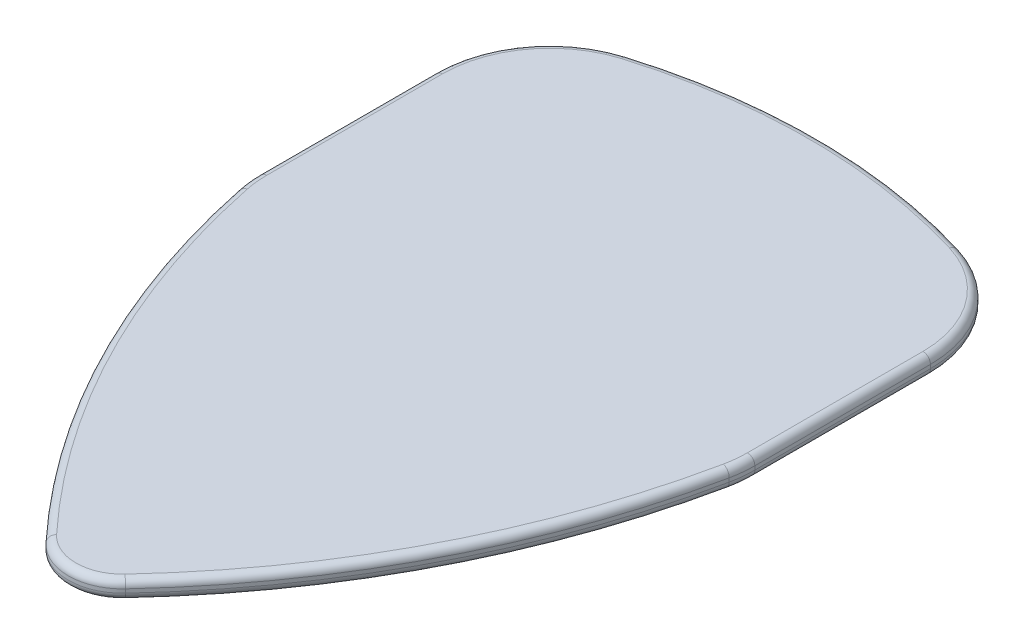
from build123d import *

# Parameters (mm, degrees)
BOSS_EXTRUDE1_DEPTH = 1
BOSS_EXTRUDE2_DEPTH = 1
FILLET1_R           = 0.4


with BuildPart() as part:
    # Sketch1 → Boss-Extrude1 (new body)
    with BuildSketch(Plane(origin=(0, 0, 0), x_dir=(1, 0, 0), z_dir=(0, 1, 0))):
        with BuildLine():
            ThreePointArc((-8.877423872, 29.304875795), (0, 30.62), (8.877423872, 29.304875795))
            ThreePointArc((8.877423872, 29.304875795), (12.375173273, 26.566048159), (13.11, 22.184786084))
            ThreePointArc((13.11, 22.184786084), (9.076207285, 10.799312083), (2.121856975, 0.92320386))
            ThreePointArc((2.121856975, 0.92320386), (0, 0), (-2.121856975, 0.92320386))
            ThreePointArc((-2.121856975, 0.92320386), (-9.076207285, 10.799312083), (-13.11, 22.184786084))
            ThreePointArc((-13.11, 22.184786084), (-12.375173273, 26.566048159), (-8.877423872, 29.304875795))
        make_face()
    extrude(amount=BOSS_EXTRUDE1_DEPTH)

    # Sketch2 → Boss-Extrude2 (add)
    with BuildSketch(Plane(origin=(0, 0, 0), x_dir=(1, 0, 0), z_dir=(0, 1, 0))):
        with BuildLine():
            Line((-13.23730034, 32.808587834), (-13.23730034, 23.428587834))
            Line((-13.23730034, 23.428587834), (13.23730034, 23.428587834))
            Line((13.23730034, 23.428587834), (13.23730034, 32.808587834))
            ThreePointArc((13.23730034, 32.808587834), (12.02830219, 36.467114963), (8.877423872, 38.684875795))
            ThreePointArc((8.877423872, 38.684875795), (0, 40), (-8.877423872, 38.684875795))
            ThreePointArc((-8.877423872, 38.684875795), (-12.02830219, 36.467114963), (-13.23730034, 32.808587834))
        make_face()
    extrude(amount=BOSS_EXTRUDE2_DEPTH)

    # Fillet1
    fillet1_edges = [part.edges().sort_by_distance(p)[0] for p in [
        (0, 1, 0),
        (9.076207285, 1, -10.799312083),
        (-13.205392346, 0, -22.803438218),
        (-13.205392346, 1, -22.803438218),
        (13.205392346, 1, -22.803438218),
        (-12.02830219, 0, -36.467114963),
        (-13.23730034, 0, -28.118587834),
        (13.23730034, 1, -28.118587834),
        (12.02830219, 0, -36.467114963),
        (0, 1, -40),
        (12.02830219, 1, -36.467114963),
        (-12.02830219, 1, -36.467114963),
        (-13.23730034, 1, -28.118587834),
        (0, 0, -40),
        (13.23730034, 0, -28.118587834),
        (13.205392346, 0, -22.803438218),
        (9.076207285, 0, -10.799312083),
        (0, 0, 0),
        (-9.076207285, 0, -10.799312083),
        (-9.076207285, 1, -10.799312083),
    ]]
    fillet(fillet1_edges, radius=FILLET1_R)


solid = part.part
